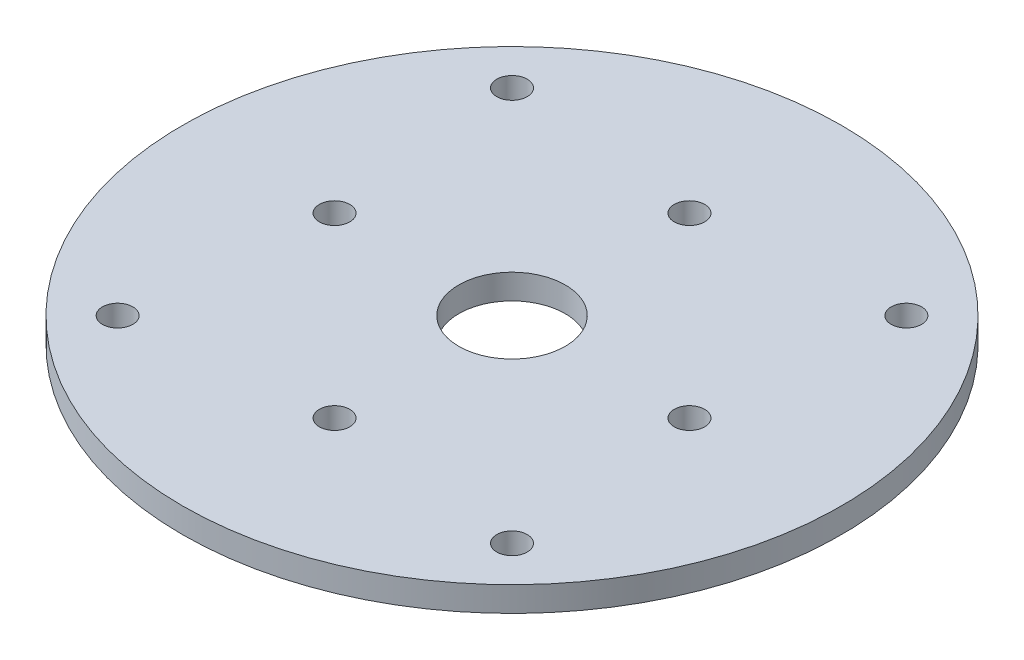
from build123d import *

# Parameters (mm, degrees)
SKETCH_1_R         = 65
SKETCH_1_R_2       = 3
SKETCH_1_R_3       = 10.5
EXTRUDE_3_DEPTH    = 4.917000374
CUT_EXTRUDE1_START = -5.917000374
SKETCH1_R          = 3
CUT_EXTRUDE1_DEPTH = 6.917000374
CIRPATTERN1_COUNT  = 4


with BuildPart() as part:
    # 草圖1 → 填料-伸長3 (new body)
    with BuildSketch(Plane(origin=(0, 0, 0), x_dir=(1, 0, 0), z_dir=(0, 1, 0))):
        Circle(SKETCH_1_R)
        with Locations((-35, 0)):
            Circle(SKETCH_1_R_2, mode=Mode.SUBTRACT)
        with Locations((35, 0)):
            Circle(SKETCH_1_R_2, mode=Mode.SUBTRACT)
        with Locations((0, -35)):
            Circle(SKETCH_1_R_2, mode=Mode.SUBTRACT)
        with Locations((0, 35)):
            Circle(SKETCH_1_R_2, mode=Mode.SUBTRACT)
        Circle(SKETCH_1_R_3, mode=Mode.SUBTRACT)
    extrude(amount=EXTRUDE_3_DEPTH)

    # Sketch1 → Cut-Extrude1 (cut)
    with BuildSketch(Plane(origin=(0, 4.917000374, 0), x_dir=(1, 0, 0), z_dir=(0, 1, 0)).offset(CUT_EXTRUDE1_START)):
        with Locations((-38.890872965, 38.890872965)):
            Circle(SKETCH1_R)
    cut_extrude1 = extrude(amount=CUT_EXTRUDE1_DEPTH, mode=Mode.SUBTRACT)

    # CirPattern1: Cut-Extrude1 ×4 about axis
    cirpattern1_axis = Axis((0, 0, 0), (0, 1, 0))
    for i in range(1, CIRPATTERN1_COUNT):
        add(cut_extrude1.rotate(cirpattern1_axis, i * 360 / CIRPATTERN1_COUNT), mode=Mode.SUBTRACT)


solid = part.part
